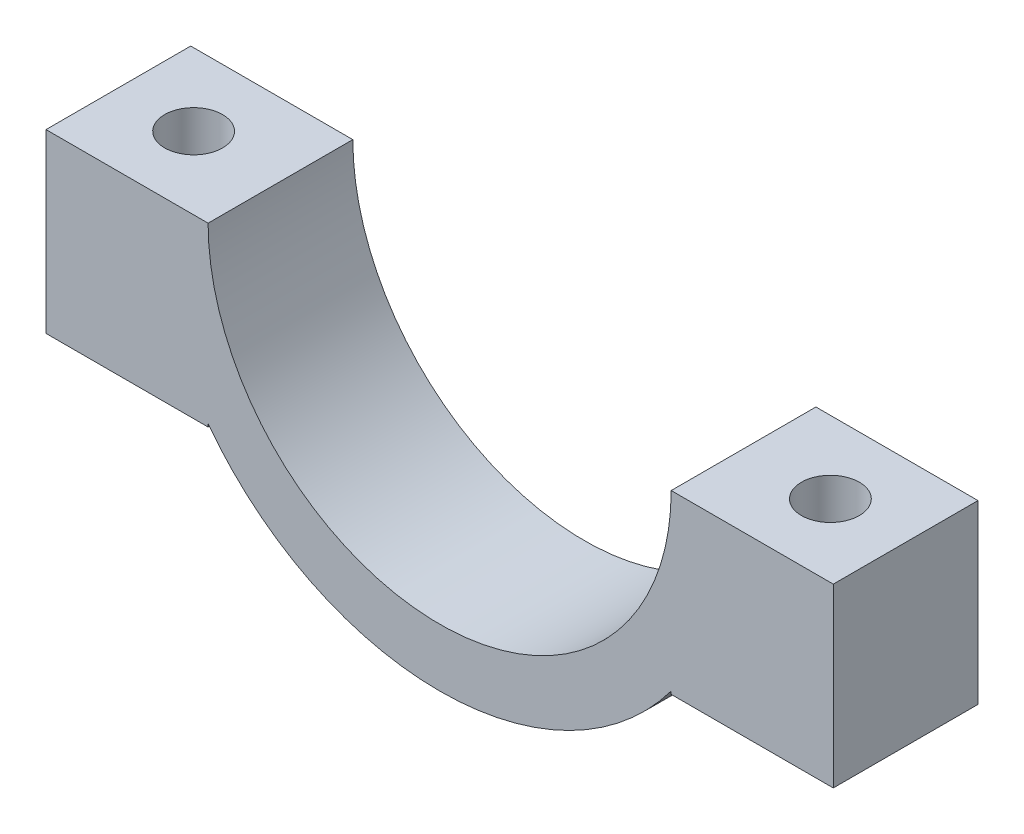
from build123d import *

# Parameters (mm, degrees)
BOSS_EXTRUDE1_DEPTH = 5
SKETCH3_R           = 1
CUT_EXTRUDE1_DEPTH  = 10


with BuildPart() as part:
    # Sketch2 → Boss-Extrude1 (new body)
    with BuildSketch(Plane.XY):
        with BuildLine():
            ThreePointArc((-8, -6), (0, -10), (8, -6))
            Line((8, -6), (8, -6.1))
            Line((8, -6.1), (13.6, -6.1))
            Line((13.6, -6.1), (13.6, 0))
            Line((13.6, 0), (8, 0))
            ThreePointArc((8, 0), (0, -8), (-8, 0))
            Line((-8, 0), (-13.6, 0))
            Line((-13.6, 0), (-13.6, -6.1))
            Line((-13.6, -6.1), (-8, -6.1))
            Line((-8, -6.1), (-8, -6))
        make_face()
    extrude(amount=BOSS_EXTRUDE1_DEPTH)

    # Sketch3 → Cut-Extrude1 (cut)
    with BuildSketch(Plane(origin=(0, 0, 0), x_dir=(1, 0, 0), z_dir=(0, 1, 0))):
        with Locations((-11, -2.5)):
            Circle(SKETCH3_R)
        with Locations((11, -2.5)):
            Circle(SKETCH3_R)
    extrude(amount=-CUT_EXTRUDE1_DEPTH, mode=Mode.SUBTRACT)


solid = part.part
